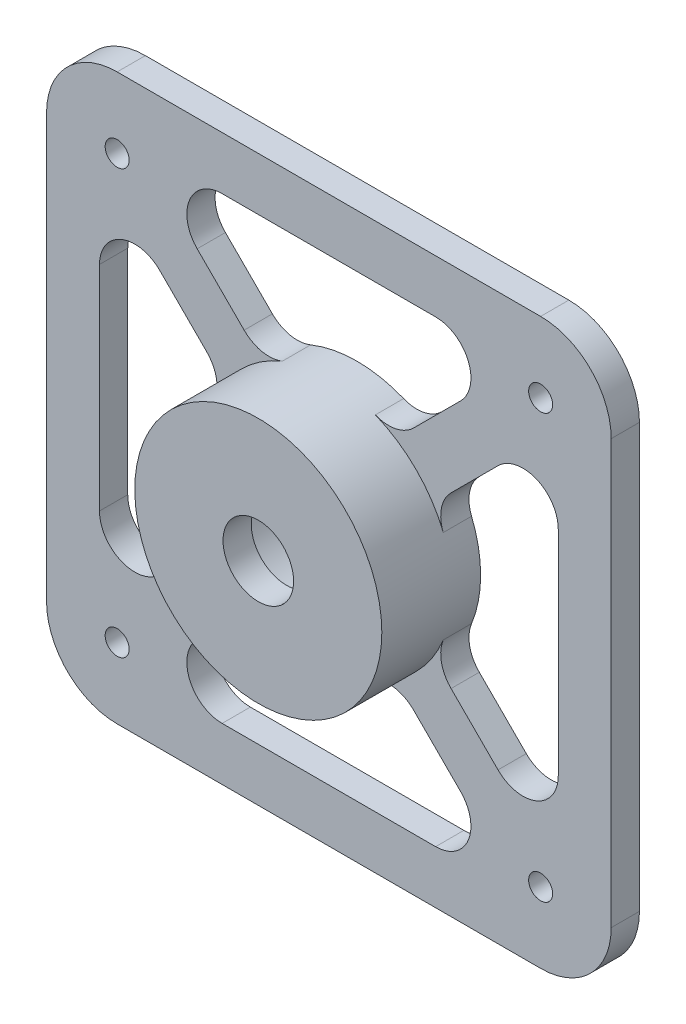
from build123d import *

# Parameters (mm, degrees)
SKETCH1_W            = 80
SKETCH1_H            = 80
BOSS_EXTRUDE1_DEPTH  = 4
CUT_EXTRUDE3_DEPTH   = 5
SKETCH8_R            = 17.5
BOSS_EXTRUDE2_DEPTH  = 10
M3_CLEARANCE_HOLE1_D = 3.4
FILLET1_R            = 10
SKETCH2_R            = 10
CUT_EXTRUDE4_DEPTH   = 10
SKETCH9_R            = 5
CUT_EXTRUDE5_DEPTH   = 15


with BuildPart() as part:
    # Sketch1 → Boss-Extrude1 (new body)
    with BuildSketch(Plane.XY):
        Rectangle(SKETCH1_W, SKETCH1_H)
    extrude(amount=BOSS_EXTRUDE1_DEPTH)

    # Sketch7 → Cut-Extrude3 (cut, through all)
    with BuildSketch(Plane(origin=(0, 0, 0), x_dir=(-1, 0, 0), z_dir=(0, 0, -1))):
        with BuildLine():
            Line((17.3092, -12.005899), (23.964466, -18.661165))
            ThreePointArc((23.964466, -18.661165), (29.413417, -19.745029), (32.5, -15.125631))
            Line((32.5, -15.125631), (32.5, 15.125631))
            ThreePointArc((32.5, 15.125631), (29.413417, 19.745029), (23.964466, 18.661165))
            Line((23.964466, 18.661165), (17.3092, 12.005899))
            ThreePointArc((17.3092, 12.005899), (15.944115, 9.462303), (16.212571, 6.588062))
            ThreePointArc((16.212571, 6.588062), (17.5, 0), (16.212571, -6.588062))
            ThreePointArc((16.212571, -6.588062), (15.944115, -9.462303), (17.3092, -12.005899))
        make_face()
        with BuildLine():
            Line((-15.125631, -32.5), (15.125631, -32.5))
            ThreePointArc((15.125631, -32.5), (19.745029, -29.413417), (18.661165, -23.964466))
            Line((18.661165, -23.964466), (12.005899, -17.3092))
            ThreePointArc((12.005899, -17.3092), (9.462303, -15.944115), (6.588062, -16.212571))
            ThreePointArc((6.588062, -16.212571), (0, -17.5), (-6.588062, -16.212571))
            ThreePointArc((-6.588062, -16.212571), (-9.462303, -15.944115), (-12.005899, -17.3092))
            Line((-12.005899, -17.3092), (-18.661165, -23.964466))
            ThreePointArc((-18.661165, -23.964466), (-19.745029, -29.413417), (-15.125631, -32.5))
        make_face()
        with BuildLine():
            Line((-32.5, -15.125631), (-32.5, 15.125631))
            ThreePointArc((-32.5, 15.125631), (-29.413417, 19.745029), (-23.964466, 18.661165))
            Line((-23.964466, 18.661165), (-17.3092, 12.005899))
            ThreePointArc((-17.3092, 12.005899), (-15.944115, 9.462303), (-16.212571, 6.588062))
            ThreePointArc((-16.212571, 6.588062), (-17.5, 0), (-16.212571, -6.588062))
            ThreePointArc((-16.212571, -6.588062), (-15.944115, -9.462303), (-17.3092, -12.005899))
            Line((-17.3092, -12.005899), (-23.964466, -18.661165))
            ThreePointArc((-23.964466, -18.661165), (-29.413417, -19.745029), (-32.5, -15.125631))
        make_face()
        with BuildLine():
            Line((-15.125631, 32.5), (15.125631, 32.5))
            ThreePointArc((15.125631, 32.5), (19.745029, 29.413417), (18.661165, 23.964466))
            Line((18.661165, 23.964466), (12.005899, 17.3092))
            ThreePointArc((12.005899, 17.3092), (9.462303, 15.944115), (6.588062, 16.212571))
            ThreePointArc((6.588062, 16.212571), (0, 17.5), (-6.588062, 16.212571))
            ThreePointArc((-6.588062, 16.212571), (-9.462303, 15.944115), (-12.005899, 17.3092))
            Line((-12.005899, 17.3092), (-18.661165, 23.964466))
            ThreePointArc((-18.661165, 23.964466), (-19.745029, 29.413417), (-15.125631, 32.5))
        make_face()
    extrude(amount=-CUT_EXTRUDE3_DEPTH, mode=Mode.SUBTRACT)

    # Sketch8 → Boss-Extrude2 (add)
    with BuildSketch(Plane.XY.offset(4)):
        Circle(SKETCH8_R)
    extrude(amount=BOSS_EXTRUDE2_DEPTH)

    # M3 Clearance Hole1 (through all)
    with Locations(Plane.XY.offset(4)):
        with Locations((-30, 30), (30, 30), (30, -30), (-30, -30)):
            Hole(M3_CLEARANCE_HOLE1_D / 2)

    # Fillet1
    fillet1_edges = [part.edges().sort_by_distance(p)[0] for p in [
        (40, -40, 2),
        (-40, -40, 2),
        (-40, 40, 2),
        (40, 40, 2),
    ]]
    fillet(fillet1_edges, radius=FILLET1_R)

    # Sketch2 → Cut-Extrude4 (cut)
    with BuildSketch(Plane.XY):
        Circle(SKETCH2_R)
    extrude(amount=CUT_EXTRUDE4_DEPTH, mode=Mode.SUBTRACT)

    # Sketch9 → Cut-Extrude5 (cut, through all)
    with BuildSketch(Plane.XY.offset(14)):
        Circle(SKETCH9_R)
    extrude(amount=-CUT_EXTRUDE5_DEPTH, mode=Mode.SUBTRACT)


solid = part.part
